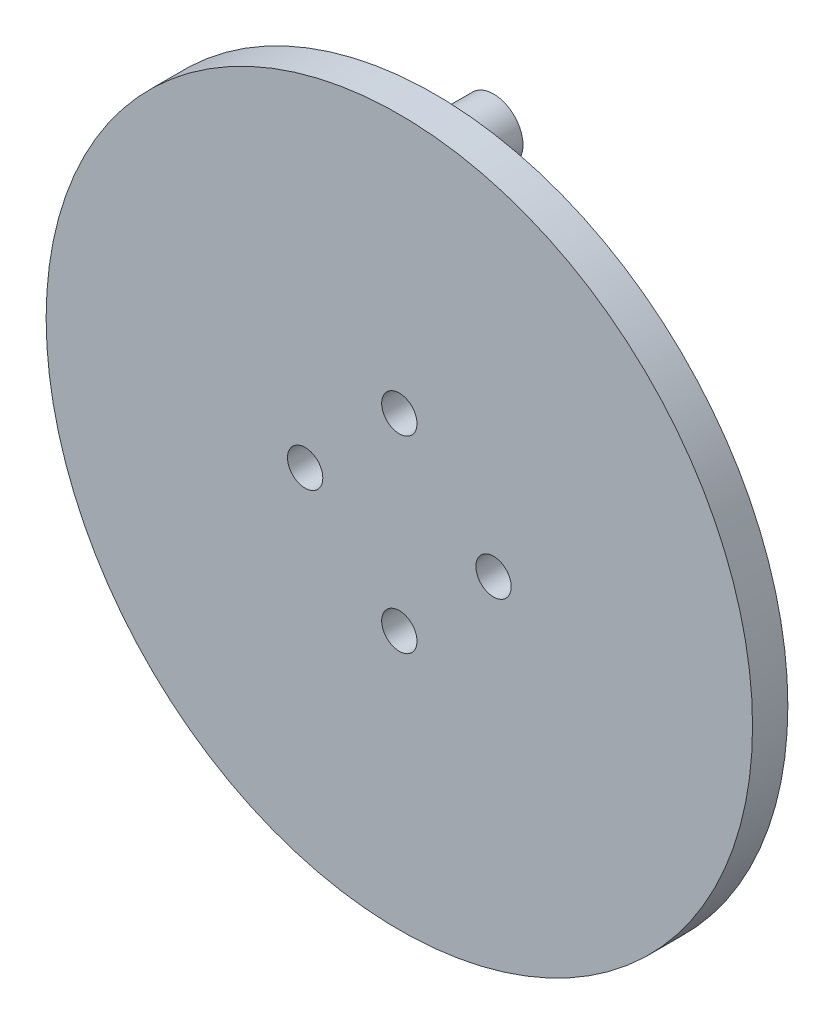
from build123d import *

# Parameters (mm, degrees)
SKETCH3_R           = 30
SKETCH3_R_2         = 1.5
BOSS_EXTRUDE2_DEPTH = 3
SKETCH4_R           = 2.5
BOSS_EXTRUDE3_DEPTH = 5


with BuildPart() as part:
    # Sketch3 → Boss-Extrude2 (new body)
    with BuildSketch(Plane.XY):
        Circle(SKETCH3_R)
        with Locations((-8, 0)):
            Circle(SKETCH3_R_2, mode=Mode.SUBTRACT)
        with Locations((0, 8)):
            Circle(SKETCH3_R_2, mode=Mode.SUBTRACT)
        with Locations((8, 0)):
            Circle(SKETCH3_R_2, mode=Mode.SUBTRACT)
        with Locations((0, -8)):
            Circle(SKETCH3_R_2, mode=Mode.SUBTRACT)
    extrude(amount=BOSS_EXTRUDE2_DEPTH)

    # Sketch4 → Boss-Extrude3 (add)
    with BuildSketch(Plane(origin=(0, 0, 0), x_dir=(-1, 0, 0), z_dir=(0, 0, -1))):
        with Locations((0, 25)):
            Circle(SKETCH4_R)
    extrude(amount=BOSS_EXTRUDE3_DEPTH)


solid = part.part
